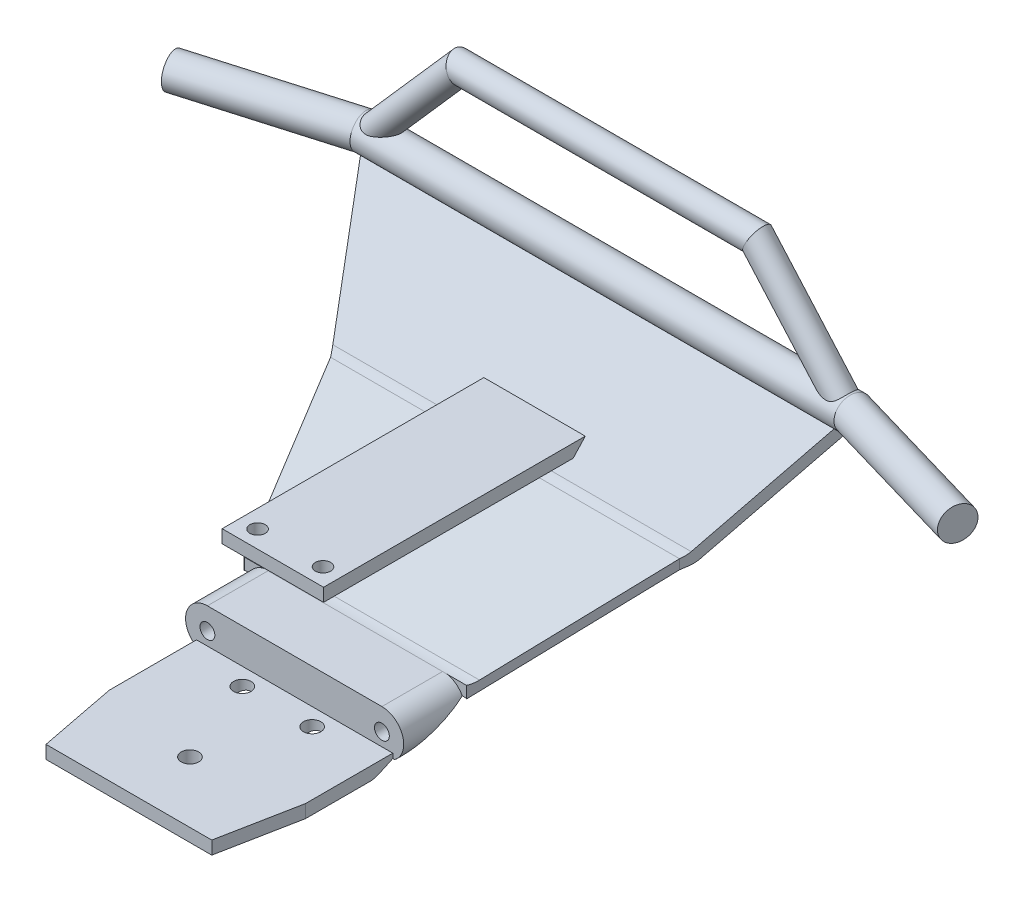
from build123d import *

# Parameters (mm, degrees)
BOSS_EXTRUDE1_DEPTH             = 57
SKETCH18_R                      = 2
CUT_EXTRUDE3_DEPTH              = 3
CUT_EXTRUDE5_DEPTH              = 60
CUT_EXTRUDE5_DEPTH_BACK         = 1.0000001
SKETCH24_R                      = 1.7
CUT_EXTRUDE6_DEPTH              = 14
SWEEP1_PROFILE_R                = 3.75
SWEEP2_PROFILE_R                = 3
BOSS_EXTRUDE2_REACH             = 77.667
SKETCH19_W                      = 23.25
SKETCH19_H                      = 3
BOSS_EXTRUDE2_DIRECTION_2_DEPTH = 5
CUT_EXTRUDE8_REACH              = 35
SKETCH54_R                      = 1.75


with BuildPart() as part:
    # Sketch2 → Boss-Extrude1 (new body, symmetric)
    with BuildSketch(Plane(origin=(0, 0, 0), x_dir=(0, 0, -1), z_dir=(1, 0, 0))):
        with BuildLine():
            Line((0, 0), (32.709545462, 0))
            ThreePointArc((32.709545462, 0), (33.775734101, 0.114998282), (34.792878796, 0.454703286))
            Line((34.792878796, 0.454703286), (87.43170835, 24.581671255))
            ThreePointArc((87.43170835, 24.581671255), (88.285761732, 25.080764899), (89.024845605, 25.738227198))
            Line((89.024845605, 25.738227198), (111.387831165, 50))
            Line((111.387831165, 50), (109.917242929, 51.355496308))
            Line((109.917242929, 51.355496308), (87.826438044, 27.389014385))
            ThreePointArc((87.826438044, 27.389014385), (87.087354171, 26.731552087), (86.233300789, 26.232458442))
            Line((86.233300789, 26.232458442), (53.992045448, 11.454703286))
            ThreePointArc((53.992045448, 11.454703286), (52.974900754, 11.114998282), (51.908712115, 11))
            Line((51.908712115, 11), (38, 11))
            Line((38, 11), (38, 3))
            Line((38, 3), (0, 3))
            Line((0, 3), (0, 0))
        make_face()
    extrude(amount=BOSS_EXTRUDE1_DEPTH, both=True)

    # Sketch18 → Cut-Extrude3 (cut)
    with BuildSketch(Plane(origin=(0, 3, 0), x_dir=(1, 0, 0), z_dir=(0, 1, 0))):
        with Locations((-8, 34)):
            Circle(SKETCH18_R)
        with Locations((8, 34)):
            Circle(SKETCH18_R)
        with Locations((0, 14)):
            Circle(SKETCH18_R)
    extrude(amount=-CUT_EXTRUDE3_DEPTH, mode=Mode.SUBTRACT)

    # Sketch23 → Cut-Extrude5 (cut, two sides)
    with BuildSketch(Plane(origin=(0, 0, 0), x_dir=(1, 0, 0), z_dir=(0, 1, 0))) as cut_extrude5_sk:
        Polygon((19, 0), (22.5, 18), (22.5, 38), (25.5, 38), (25.5, 51.908712115), (40, 86.233300789), (57, 111.387831165), (57, 0), align=None)
        Polygon((-57, 0), (-19, 0), (-22.5, 18), (-22.5, 38), (-25.5, 38), (-25.5, 51.908712115), (-40, 86.233300789), (-57, 111.387831165), align=None)
    extrude(amount=CUT_EXTRUDE5_DEPTH, mode=Mode.SUBTRACT)
    extrude(cut_extrude5_sk.sketch, amount=-CUT_EXTRUDE5_DEPTH_BACK, mode=Mode.SUBTRACT)

    # Sketch24 → Cut-Extrude6 (cut)
    with BuildSketch(Plane.XY.offset(-38)):
        with Locations((-20, 6)):
            Circle(SKETCH24_R)
        with Locations((20, 6)):
            Circle(SKETCH24_R)
        with BuildLine():
            Line((-20, 11), (-25.5, 11))
            Line((-25.5, 11), (-25.5, 1.924684879))
            Line((-25.5, 1.924684879), (-22.89686152, 1.924684879))
            ThreePointArc((-22.89686152, 1.924684879), (-24.763222418, 7.520431583), (-20, 11))
        make_face()
        with BuildLine():
            Line((22.89686152, 1.924684879), (25.5, 1.924684879))
            Line((25.5, 1.924684879), (25.5, 11))
            Line((25.5, 11), (20, 11))
            ThreePointArc((20, 11), (24.763222418, 7.520431583), (22.89686152, 1.924684879))
        make_face()
    extrude(amount=-CUT_EXTRUDE6_DEPTH, mode=Mode.SUBTRACT)

    # Sweep1: sweep along a curve in space
    with BuildLine() as sweep1_path:
        Line((-90, 51.35, -100), (-56.006143242, 51.355496308, -109.917242929))
        Line((-56.006143242, 51.355496308, -109.917242929), (56.006143242, 51.355496308, -109.917242929))
        Line((56.006143242, 51.355496308, -109.917242929), (90, 51.35, -100))
    # Sweep1 profile (on start of the path) → Sweep1 (sweep)
    with BuildSketch(Plane(origin=(-90, 51.35, -100), x_dir=(0.28006163, 0, 0.959982023), z_dir=(0.959982011, 0.000155215, -0.280061626))):
        Circle(SWEEP1_PROFILE_R)
    sweep(path=sweep1_path.line, transition=Transition.RIGHT)

    # Sweep2: sweep along a curve in space
    with BuildLine() as sweep2_path:
        Line((-56, 50, -110), (-34, 75, -110))
        Line((-34, 75, -110), (34, 75, -110))
        Line((34, 75, -110), (56, 50, -110))
    # Sweep2 profile (on start of the path) → Sweep2 (sweep)
    with BuildSketch(Plane(origin=(-56, 50, -110), x_dir=(0.750713517, -0.660627895, 0), z_dir=(0.660627895, 0.750713517, 0))):
        Circle(SWEEP2_PROFILE_R)
    sweep(path=sweep2_path.line, transition=Transition.RIGHT)

    # Boss-Extrude2: up to this face of the body (flat: up to its plane)
    boss_extrude2_end = Plane(part.part.faces().sort_by_distance((0, 38.483295154, -98.05245255))[0])
    # Sketch19 → Boss-Extrude2 (add, up to the picked face)
    with BuildSketch(Plane.XY.offset(-38), mode=Mode.PRIVATE) as boss_extrude2_sk1:
        with Locations((0, 31.5)):
            Rectangle(SKETCH19_W, SKETCH19_H)
    boss_extrude2_tool1 = split(extrude(boss_extrude2_sk1.sketch, amount=-BOSS_EXTRUDE2_REACH, mode=Mode.PRIVATE), bisect_by=boss_extrude2_end, keep=Keep.BOTH, mode=Mode.PRIVATE)
    add(boss_extrude2_tool1.solids().sort_by_distance((0, 31.5, -38))[0])

    # Sketch19 → Boss-Extrude2 direction 2 (add)
    with BuildSketch(Plane.XY.offset(-38)):
        with Locations((0, 31.5)):
            Rectangle(SKETCH19_W, SKETCH19_H)
    extrude(amount=BOSS_EXTRUDE2_DIRECTION_2_DEPTH)

    # Sketch54 → Cut-Extrude8 (cut, up to next)
    with BuildSketch(Plane(origin=(0, 33, 0), x_dir=(1, 0, 0), z_dir=(0, 1, 0)), mode=Mode.PRIVATE) as cut_extrude8_sk1:
        with Locations((-7.5, 37)):
            Circle(SKETCH54_R)
    cut_extrude8_tool1 = extrude(cut_extrude8_sk1.sketch, amount=-CUT_EXTRUDE8_REACH, mode=Mode.PRIVATE) & part.part
    add(cut_extrude8_tool1.solids().sort_by_distance((-7.5, 33, -37))[0], mode=Mode.SUBTRACT)
    # Sketch54 → Cut-Extrude8 (cut, up to next)
    with BuildSketch(Plane(origin=(0, 33, 0), x_dir=(1, 0, 0), z_dir=(0, 1, 0)), mode=Mode.PRIVATE) as cut_extrude8_sk2:
        with Locations((7.5, 37)):
            Circle(SKETCH54_R)
    cut_extrude8_tool2 = extrude(cut_extrude8_sk2.sketch, amount=-CUT_EXTRUDE8_REACH, mode=Mode.PRIVATE) & part.part
    add(cut_extrude8_tool2.solids().sort_by_distance((7.5, 33, -37))[0], mode=Mode.SUBTRACT)


solid = part.part
